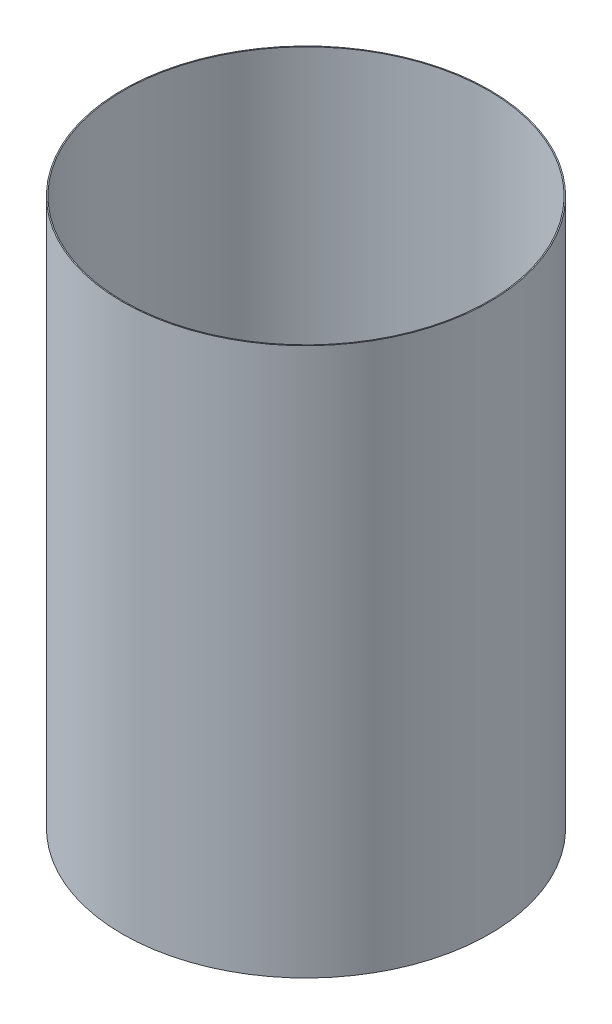
from build123d import *

# Parameters (mm, degrees)
SKETCH1_W = 0.254
SKETCH1_H = 133.35


with BuildPart() as part:
    # Sketch1 → Revolve-Thin1 (revolve)
    with BuildSketch(Plane.XY):
        with Locations((-44.577, -135.67819341)):
            Rectangle(SKETCH1_W, SKETCH1_H)
    revolve(axis=Axis((0, 55, 0), (0, -1, 0)))


solid = part.part
